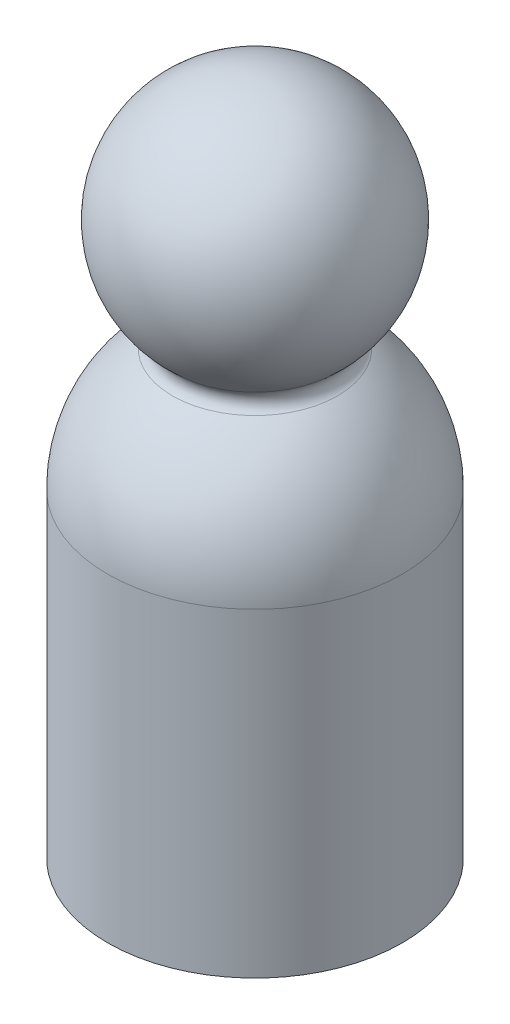
from build123d import *

# Parameters (mm, degrees)
FILLET_1_R = 1


with BuildPart() as part:
    # 草圖1 → 旋轉1 (revolve)
    with BuildSketch(Plane.XY):
        with BuildLine():
            Line((0, 24.569711538), (0, -30.430288462))
            Line((0, -30.430288462), (-12, -30.430288462))
            Line((-12, -30.430288462), (-12, -4.430288462))
            ThreePointArc((-12, -4.430288462), (-10.25118363, 1.807758844), (-5.514460969, 6.227606275))
            ThreePointArc((-5.514460969, 6.227606275), (-9.576561299, 17.448856148), (0, 24.569711538))
        make_face()
    revolve(axis=Axis((0, -20.689903846, 0), (0, 1, 0)))

    # 圓角1
    fillet_1_edges = [part.edges().sort_by_distance(p)[0] for p in [
        (5.514460969, 6.227606275, 0),
    ]]
    fillet(fillet_1_edges, radius=FILLET_1_R)


solid = part.part
